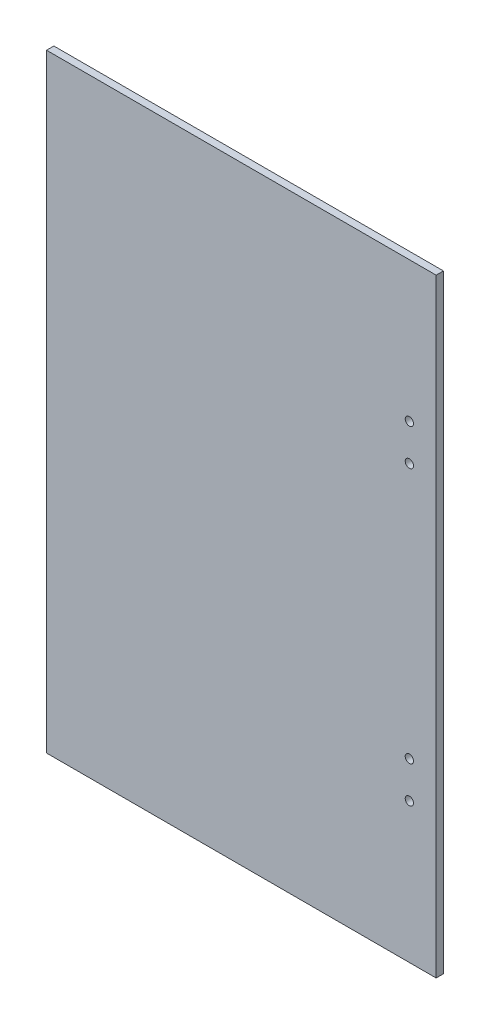
from build123d import *

# Parameters (mm, degrees)
ESQUISSE1_W             = 160
ESQUISSE1_H             = 250
BOSS_EXTRU_1_DEPTH      = 1.5
ESQUISSE2_R             = 1.7
ENL_V_MAT_EXTRU_1_DEPTH = 4


with BuildPart() as part:
    # Esquisse1 → Boss.-Extru.1 (new body, symmetric)
    with BuildSketch(Plane.XY):
        Rectangle(ESQUISSE1_W, ESQUISSE1_H)
    extrude(amount=BOSS_EXTRU_1_DEPTH, both=True)

    # Esquisse2 → Enlèv. mat.-Extru.1 (cut, through all)
    with BuildSketch(Plane.XY.offset(1.5)):
        with Locations((69, 67.5)):
            Circle(ESQUISSE2_R)
        with Locations((69, 52.5)):
            Circle(ESQUISSE2_R)
        with Locations((69, -52.5)):
            Circle(ESQUISSE2_R)
        with Locations((69, -67.5)):
            Circle(ESQUISSE2_R)
    extrude(amount=-ENL_V_MAT_EXTRU_1_DEPTH, mode=Mode.SUBTRACT)


solid = part.part
